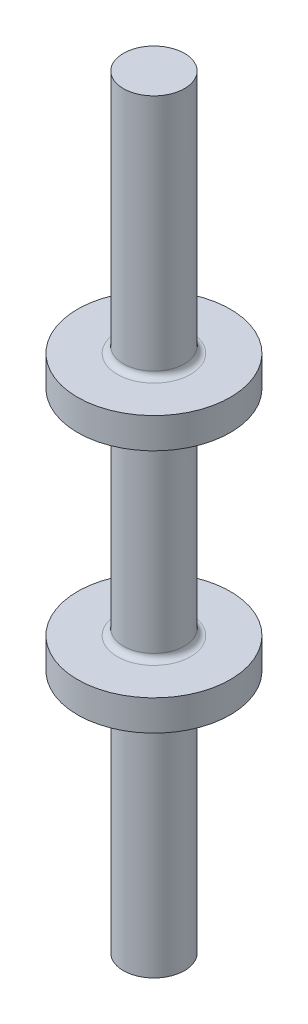
from build123d import *

# Parameters (mm, degrees)
FILLET1_R = 0.2


with BuildPart() as part:
    # Sketch1 → Revolve1 (revolve)
    with BuildSketch(Plane.XY):
        Polygon((0, 0), (1, 0), (1, 8), (2.5, 8), (2.5, 9), (1, 9), (1, 16), (2.5, 16), (2.5, 17), (1, 17), (1, 25), (0, 25), align=None)
    revolve(axis=Axis((0, 25, 0), (0, -1, 0)))

    # Fillet1
    fillet1_edges = [part.edges().sort_by_distance(p)[0] for p in [
        (-1, 17, 0),
        (-1, 16, 0),
        (-1, 9, 0),
        (-1, 8, 0),
    ]]
    fillet(fillet1_edges, radius=FILLET1_R)


solid = part.part
